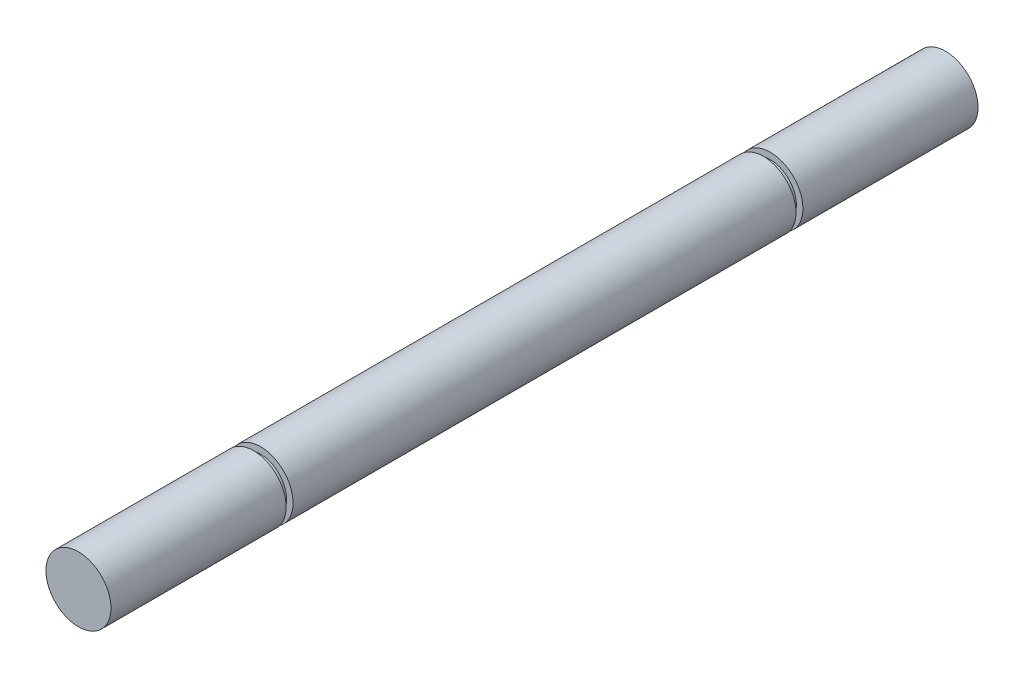
from build123d import *

# Parameters (mm, degrees)
SKETCH1_R           = 4.7625
BOSS_EXTRUDE1_DEPTH = 73.66
SKETCH2_R           = 3.81
BOSS_EXTRUDE2_DEPTH = 1.016
SKETCH3_R           = 4.7625
BOSS_EXTRUDE3_DEPTH = 25.654
SKETCH4_R           = 3.81
BOSS_EXTRUDE4_DEPTH = 1.016
SKETCH5_R           = 4.7625
BOSS_EXTRUDE5_DEPTH = 25.654


with BuildPart() as part:
    # Sketch1 → Boss-Extrude1 (new body)
    with BuildSketch(Plane.XY):
        Circle(SKETCH1_R)
    extrude(amount=BOSS_EXTRUDE1_DEPTH)

    # Sketch2 → Boss-Extrude2 (add)
    with BuildSketch(Plane(origin=(0, 0, 0), x_dir=(-1, 0, 0), z_dir=(0, 0, -1))):
        Circle(SKETCH2_R)
    extrude(amount=BOSS_EXTRUDE2_DEPTH)

    # Sketch3 → Boss-Extrude3 (add)
    with BuildSketch(Plane(origin=(0, 0, -1.016), x_dir=(-1, 0, 0), z_dir=(0, 0, -1))):
        Circle(SKETCH3_R)
    extrude(amount=BOSS_EXTRUDE3_DEPTH)

    # Sketch4 → Boss-Extrude4 (add)
    with BuildSketch(Plane.XY.offset(73.66)):
        Circle(SKETCH4_R)
    extrude(amount=BOSS_EXTRUDE4_DEPTH)

    # Sketch5 → Boss-Extrude5 (add)
    with BuildSketch(Plane.XY.offset(74.676)):
        Circle(SKETCH5_R)
    extrude(amount=BOSS_EXTRUDE5_DEPTH)


solid = part.part
